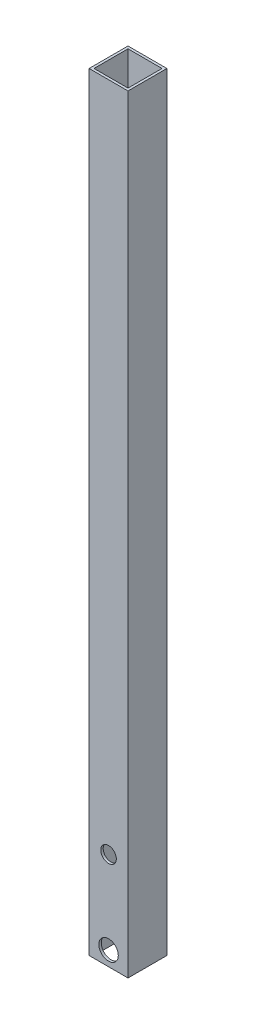
from build123d import *

# Parameters (mm, degrees)
SKETCH1_W           = 25.4
SKETCH1_H           = 25.4
SKETCH1_W_2         = 22.225
SKETCH1_H_2         = 22.225
BOSS_EXTRUDE1_DEPTH = 501.65
SKETCH4_R           = 6.35
CUT_EXTRUDE1_DEPTH  = 26.4
SKETCH7_R           = 5.08
CUT_EXTRUDE3_DEPTH  = 1.5875


with BuildPart() as part:
    # Sketch1 → Boss-Extrude1 (new body)
    with BuildSketch(Plane(origin=(0, 0, 0), x_dir=(1, 0, 0), z_dir=(0, 1, 0))):
        Rectangle(SKETCH1_W, SKETCH1_H)
        Rectangle(SKETCH1_W_2, SKETCH1_H_2, mode=Mode.SUBTRACT)
    extrude(amount=BOSS_EXTRUDE1_DEPTH)

    # Sketch4 → Cut-Extrude1 (cut, through all)
    with BuildSketch(Plane.XY.offset(12.7)):
        with Locations((0, 9.525)):
            Circle(SKETCH4_R)
    extrude(amount=-CUT_EXTRUDE1_DEPTH, mode=Mode.SUBTRACT)

    # Sketch7 → Cut-Extrude3 (cut)
    with BuildSketch(Plane.XY.offset(12.7)):
        with Locations((0, 63.5)):
            Circle(SKETCH7_R)
    extrude(amount=-CUT_EXTRUDE3_DEPTH, mode=Mode.SUBTRACT)


solid = part.part
